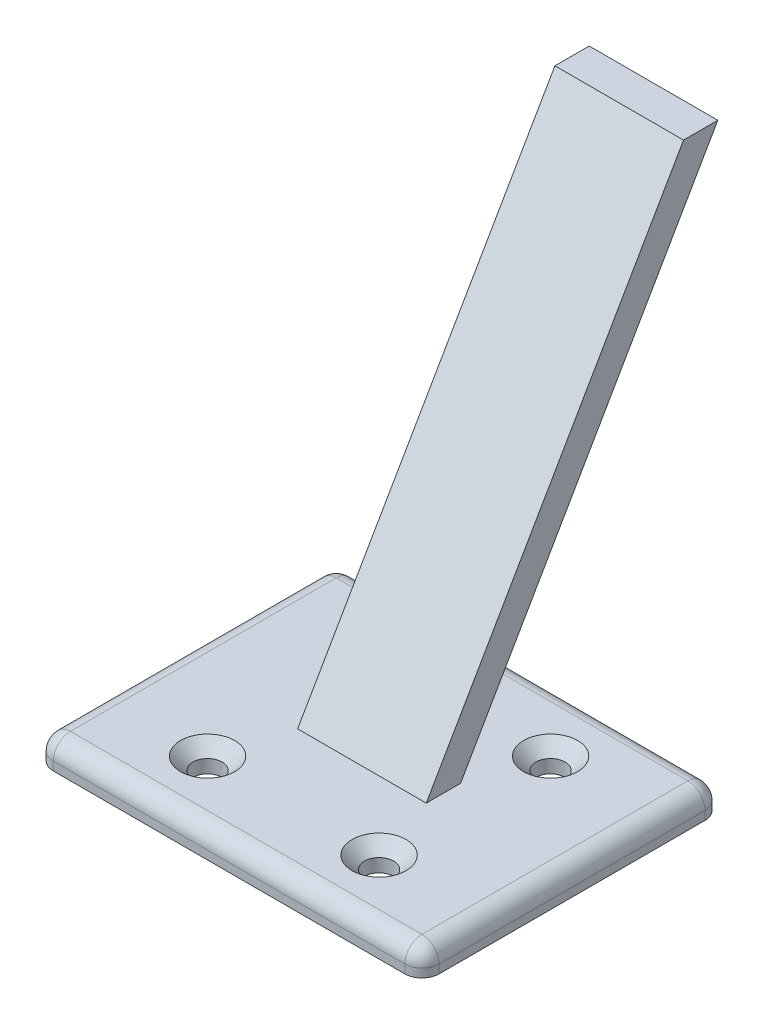
from build123d import *

# Parameters (mm, degrees)
SKETCH1_W                                      = 45
SKETCH1_H                                      = 35
BOSS_EXTRUDE1_DEPTH                            = 3
CSK_FOR_M3_FLAT_HEAD_MACHINE_SCREW2_AT_2_COUNT = 2
CSK_FOR_M3_FLAT_HEAD_MACHINE_SCREW2_AT_2_PITCH = 20
CSK_FOR_M3_FLAT_HEAD_MACHINE_SCREW2_AT_3_COUNT = 2
CSK_FOR_M3_FLAT_HEAD_MACHINE_SCREW2_AT_3_PITCH = 28.284271247
CSK_FOR_M3_FLAT_HEAD_MACHINE_SCREW2_AT_4_COUNT = 2
CSK_FOR_M3_FLAT_HEAD_MACHINE_SCREW2_AT_4_PITCH = 20
SKETCH7_W                                      = 15
SKETCH7_H                                      = 4
BOSS_EXTRUDE2_DEPTH                            = 60
FILLET1_R                                      = 2


with BuildPart() as part:
    # Sketch1 → Boss-Extrude1 (new body)
    with BuildSketch(Plane(origin=(0, 0, 0), x_dir=(1, 0, 0), z_dir=(0, 1, 0))):
        Rectangle(SKETCH1_W, SKETCH1_H)
    extrude(amount=BOSS_EXTRUDE1_DEPTH)

    # Sketch5 → CSK for M3 Flat Head Machine Screw2 (revolve, cut)
    with BuildSketch(Plane(origin=(10, 3, -10), x_dir=(0, 0, 1), z_dir=(1, 0, 0))):
        Polygon((0, 0), (0, 3), (1.7, 3), (1.7, 1.45), (3.15, 0), align=None)
    csk_for_m3_flat_head_machine_screw2 = revolve(axis=Axis((10, 9.35, -10), (0, -1, 0)), mode=Mode.SUBTRACT)

    # CSK for M3 Flat Head Machine Screw2 at 2: CSK for M3 Flat Head Machine Screw2 ×2
    with Locations(*[(-i * CSK_FOR_M3_FLAT_HEAD_MACHINE_SCREW2_AT_2_PITCH, 0, 0) for i in range(1, CSK_FOR_M3_FLAT_HEAD_MACHINE_SCREW2_AT_2_COUNT)]):
        add(csk_for_m3_flat_head_machine_screw2, mode=Mode.SUBTRACT)

    # CSK for M3 Flat Head Machine Screw2 at 3: CSK for M3 Flat Head Machine Screw2 ×2
    with Locations(*[Vector(-0.707106781, 0, 0.707106781) * (i * CSK_FOR_M3_FLAT_HEAD_MACHINE_SCREW2_AT_3_PITCH) for i in range(1, CSK_FOR_M3_FLAT_HEAD_MACHINE_SCREW2_AT_3_COUNT)]):
        add(csk_for_m3_flat_head_machine_screw2, mode=Mode.SUBTRACT)

    # CSK for M3 Flat Head Machine Screw2 at 4: CSK for M3 Flat Head Machine Screw2 ×2
    with Locations(*[(0, 0, i * CSK_FOR_M3_FLAT_HEAD_MACHINE_SCREW2_AT_4_PITCH) for i in range(1, CSK_FOR_M3_FLAT_HEAD_MACHINE_SCREW2_AT_4_COUNT)]):
        add(csk_for_m3_flat_head_machine_screw2, mode=Mode.SUBTRACT)

    # Sketch7 → Boss-Extrude2 (add, along a direction that is not the sketch's normal)
    with BuildSketch(Plane(origin=(0, 3, 0), x_dir=(1, 0, 0), z_dir=(0, 1, 0))):
        Rectangle(SKETCH7_W, SKETCH7_H)
    extrude(amount=BOSS_EXTRUDE2_DEPTH, dir=(0, 0.866025404, -0.5))

    # Fillet1
    fillet1_edges = [part.edges().sort_by_distance(p)[0] for p in [
        (22.5, 3, 0),
        (0, 3, -17.5),
        (-22.5, 3, 0),
        (0, 3, 17.5),
        (-22.5, 1.5, -17.5),
        (22.5, 1.5, -17.5),
        (22.5, 1.5, 17.5),
        (-22.5, 1.5, 17.5),
    ]]
    fillet(fillet1_edges, radius=FILLET1_R)


solid = part.part
